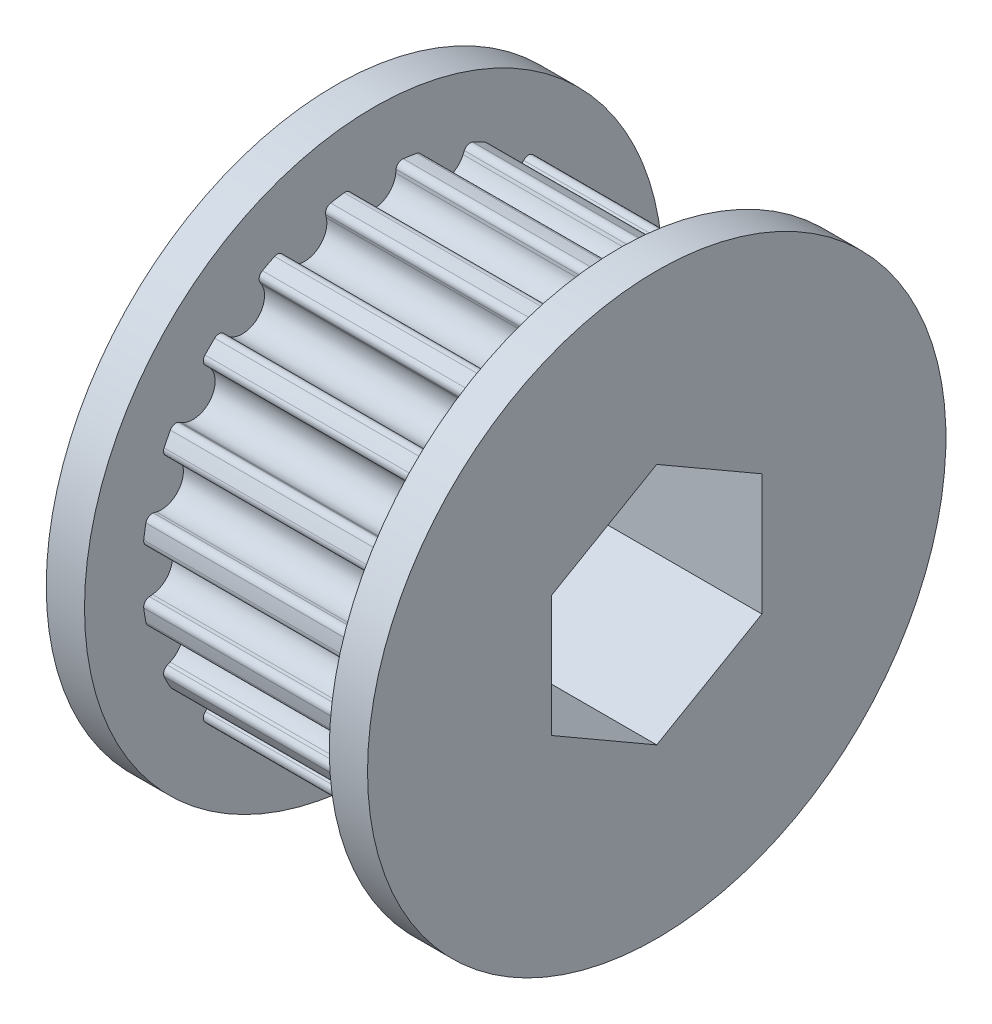
from build123d import *

# Parameters (mm, degrees)
SKETCH1_W           = 2.54
SKETCH1_H           = 19.205451693
BOSS_EXTRUDE1_DEPTH = 16.256
SKETCH3_R           = 19.205451693
BOSS_EXTRUDE2_DEPTH = 2.54
CUT_EXTRUDE1_DEPTH  = 22.336
FILLET1_R           = 0.42


with BuildPart() as part:
    # Sketch1 → Revolve1 (revolve)
    with BuildSketch(Plane(origin=(0, 0, 0), x_dir=(-1, 0, 0), z_dir=(0, 0, -1))):
        with Locations((-17.526, 9.602725847)):
            Rectangle(SKETCH1_W, SKETCH1_H)
    revolve(axis=Axis((18.796, 0, 0), (-1, 0, 0)))

    # Sketch2 → Boss-Extrude1 (add)
    with BuildSketch(Plane.ZY.offset(-16.256)):
        with BuildLine():
            Line((-14.690370829, 1.465919557), (-15.319368539, 1.528685845))
            ThreePointArc((-15.319368539, 1.528685845), (-15.205908136, 2.40837925), (-15.04197518, 3.280078587))
            Line((-15.04197518, 3.280078587), (-14.424366959, 3.145401892))
            ThreePointArc((-14.424366959, 3.145401892), (-12.709397813, 4.129533677), (-13.518378848, 5.933746587))
            Line((-13.518378848, 5.933746587), (-14.097195369, 6.187811856))
            ThreePointArc((-14.097195369, 6.187811856), (-13.717447902, 6.989388808), (-13.292168486, 7.767766074))
            Line((-13.292168486, 7.767766074), (-12.746405551, 7.448829489))
            ThreePointArc((-12.746405551, 7.448829489), (-10.811259523, 7.854839825), (-11.023113757, 9.820737158))
            Line((-11.023113757, 9.820737158), (-11.495090496, 10.241231729))
            ThreePointArc((-11.495090496, 10.241231729), (-10.886228292, 10.886228292), (-10.241231729, 11.495090496))
            Line((-10.241231729, 11.495090496), (-9.820737158, 11.023113757))
            ThreePointArc((-9.820737158, 11.023113757), (-7.854839825, 10.811259523), (-7.448829489, 12.746405551))
            Line((-7.448829489, 12.746405551), (-7.767766074, 13.292168486))
            ThreePointArc((-7.767766074, 13.292168486), (-6.989388808, 13.717447902), (-6.187811856, 14.097195369))
            Line((-6.187811856, 14.097195369), (-5.933746587, 13.518378848))
            ThreePointArc((-5.933746587, 13.518378848), (-4.129533677, 12.709397813), (-3.145401892, 14.424366959))
            Line((-3.145401892, 14.424366959), (-3.280078587, 15.04197518))
            ThreePointArc((-3.280078587, 15.04197518), (-2.40837925, 15.205908136), (-1.528685845, 15.319368539))
            Line((-1.528685845, 15.319368539), (-1.465919557, 14.690370829))
            ThreePointArc((-1.465919557, 14.690370829), (0, 13.363451693), (1.465919557, 14.690370829))
            Line((1.465919557, 14.690370829), (1.528685845, 15.319368539))
            ThreePointArc((1.528685845, 15.319368539), (2.40837925, 15.205908136), (3.280078587, 15.04197518))
            Line((3.280078587, 15.04197518), (3.145401892, 14.424366959))
            ThreePointArc((3.145401892, 14.424366959), (4.129533677, 12.709397813), (5.933746587, 13.518378848))
            Line((5.933746587, 13.518378848), (6.187811856, 14.097195369))
            ThreePointArc((6.187811856, 14.097195369), (6.989388808, 13.717447902), (7.767766074, 13.292168486))
            Line((7.767766074, 13.292168486), (7.448829489, 12.746405551))
            ThreePointArc((7.448829489, 12.746405551), (7.854839825, 10.811259523), (9.820737158, 11.023113757))
            Line((9.820737158, 11.023113757), (10.241231729, 11.495090496))
            ThreePointArc((10.241231729, 11.495090496), (10.886228292, 10.886228292), (11.495090496, 10.241231729))
            Line((11.495090496, 10.241231729), (11.023113757, 9.820737158))
            ThreePointArc((11.023113757, 9.820737158), (10.811259523, 7.854839825), (12.746405551, 7.448829489))
            Line((12.746405551, 7.448829489), (13.292168486, 7.767766074))
            ThreePointArc((13.292168486, 7.767766074), (13.717447902, 6.989388808), (14.097195369, 6.187811856))
            Line((14.097195369, 6.187811856), (13.518378848, 5.933746587))
            ThreePointArc((13.518378848, 5.933746587), (12.709397813, 4.129533677), (14.424366959, 3.145401892))
            Line((14.424366959, 3.145401892), (15.04197518, 3.280078587))
            ThreePointArc((15.04197518, 3.280078587), (15.205908136, 2.40837925), (15.319368539, 1.528685845))
            Line((15.319368539, 1.528685845), (14.690370829, 1.465919557))
            ThreePointArc((14.690370829, 1.465919557), (13.363451693, 0), (14.690370829, -1.465919557))
            Line((14.690370829, -1.465919557), (15.319368539, -1.528685845))
            ThreePointArc((15.319368539, -1.528685845), (15.205908136, -2.40837925), (15.04197518, -3.280078587))
            Line((15.04197518, -3.280078587), (14.424366959, -3.145401892))
            ThreePointArc((14.424366959, -3.145401892), (12.709397813, -4.129533677), (13.518378848, -5.933746587))
            Line((13.518378848, -5.933746587), (14.097195369, -6.187811856))
            ThreePointArc((14.097195369, -6.187811856), (13.717447902, -6.989388808), (13.292168486, -7.767766074))
            Line((13.292168486, -7.767766074), (12.746405551, -7.448829489))
            ThreePointArc((12.746405551, -7.448829489), (10.811259523, -7.854839825), (11.023113757, -9.820737158))
            Line((11.023113757, -9.820737158), (11.495090496, -10.241231729))
            ThreePointArc((11.495090496, -10.241231729), (10.886228292, -10.886228292), (10.241231729, -11.495090496))
            Line((10.241231729, -11.495090496), (9.820737158, -11.023113757))
            ThreePointArc((9.820737158, -11.023113757), (7.854839825, -10.811259523), (7.448829489, -12.746405551))
            Line((7.448829489, -12.746405551), (7.767766074, -13.292168486))
            ThreePointArc((7.767766074, -13.292168486), (6.989388808, -13.717447902), (6.187811856, -14.097195369))
            Line((6.187811856, -14.097195369), (5.933746587, -13.518378848))
            ThreePointArc((5.933746587, -13.518378848), (4.129533677, -12.709397813), (3.145401892, -14.424366959))
            Line((3.145401892, -14.424366959), (3.280078587, -15.04197518))
            ThreePointArc((3.280078587, -15.04197518), (2.40837925, -15.205908136), (1.528685845, -15.319368539))
            Line((1.528685845, -15.319368539), (1.465919557, -14.690370829))
            ThreePointArc((1.465919557, -14.690370829), (0, -13.363451693), (-1.465919557, -14.690370829))
            Line((-1.465919557, -14.690370829), (-1.528685845, -15.319368539))
            ThreePointArc((-1.528685845, -15.319368539), (-2.40837925, -15.205908136), (-3.280078587, -15.04197518))
            Line((-3.280078587, -15.04197518), (-3.145401892, -14.424366959))
            ThreePointArc((-3.145401892, -14.424366959), (-4.129533677, -12.709397813), (-5.933746587, -13.518378848))
            Line((-5.933746587, -13.518378848), (-6.187811856, -14.097195369))
            ThreePointArc((-6.187811856, -14.097195369), (-6.989388808, -13.717447902), (-7.767766074, -13.292168486))
            Line((-7.767766074, -13.292168486), (-7.448829489, -12.746405551))
            ThreePointArc((-7.448829489, -12.746405551), (-7.854839825, -10.811259523), (-9.820737158, -11.023113757))
            Line((-9.820737158, -11.023113757), (-10.241231729, -11.495090496))
            ThreePointArc((-10.241231729, -11.495090496), (-10.886228292, -10.886228292), (-11.495090496, -10.241231729))
            Line((-11.495090496, -10.241231729), (-11.023113757, -9.820737158))
            ThreePointArc((-11.023113757, -9.820737158), (-10.811259523, -7.854839825), (-12.746405551, -7.448829489))
            Line((-12.746405551, -7.448829489), (-13.292168486, -7.767766074))
            ThreePointArc((-13.292168486, -7.767766074), (-13.717447902, -6.989388808), (-14.097195369, -6.187811856))
            Line((-14.097195369, -6.187811856), (-13.518378848, -5.933746587))
            ThreePointArc((-13.518378848, -5.933746587), (-12.709397813, -4.129533677), (-14.424366959, -3.145401892))
            Line((-14.424366959, -3.145401892), (-15.04197518, -3.280078587))
            ThreePointArc((-15.04197518, -3.280078587), (-15.205908136, -2.40837925), (-15.319368539, -1.528685845))
            Line((-15.319368539, -1.528685845), (-14.690370829, -1.465919557))
            ThreePointArc((-14.690370829, -1.465919557), (-13.363451693, 0), (-14.690370829, 1.465919557))
        make_face()
    extrude(amount=BOSS_EXTRUDE1_DEPTH)

    # Sketch3 → Boss-Extrude2 (add)
    with BuildSketch(Plane(origin=(0, 0, 0), x_dir=(0, 0, -1), z_dir=(1, 0, 0))):
        Circle(SKETCH3_R)
    extrude(amount=-BOSS_EXTRUDE2_DEPTH)

    # Sketch4 → Cut-Extrude1 (cut, through all)
    with BuildSketch(Plane.ZY.offset(2.54)):
        Polygon((0, 8.065583261), (-6.985, 4.03279163), (-6.985, -4.03279163), (0, -8.065583261), (6.985, -4.03279163), (6.985, 4.03279163), align=None)
    extrude(amount=-CUT_EXTRUDE1_DEPTH, mode=Mode.SUBTRACT)

    # Fillet1
    fillet1_edges = [part.edges().sort_by_distance(p)[0] for p in [
        (8.128, -1.528685845, -15.319368539),
        (8.128, -3.280078587, -15.04197518),
        (8.128, -6.187811856, -14.097195369),
        (8.128, -7.767766074, -13.292168486),
        (8.128, -10.241231729, -11.495090496),
        (8.128, -11.495090496, -10.241231729),
        (8.128, -13.292168486, -7.767766074),
        (8.128, -14.097195369, -6.187811856),
        (8.128, -15.04197518, -3.280078587),
        (8.128, -15.319368539, -1.528685845),
        (8.128, -15.319368539, 1.528685845),
        (8.128, -15.04197518, 3.280078587),
        (8.128, -14.097195369, 6.187811856),
        (8.128, -13.292168486, 7.767766074),
        (8.128, -11.495090496, 10.241231729),
        (8.128, -10.241231729, 11.495090496),
        (8.128, -7.767766074, 13.292168486),
        (8.128, -6.187811856, 14.097195369),
        (8.128, -3.280078587, 15.04197518),
        (8.128, -1.528685845, 15.319368539),
        (8.128, 1.528685845, 15.319368539),
        (8.128, 3.280078587, 15.04197518),
        (8.128, 6.187811856, 14.097195369),
        (8.128, 7.767766074, 13.292168486),
        (8.128, 10.241231729, 11.495090496),
        (8.128, 11.495090496, 10.241231729),
        (8.128, 13.292168486, 7.767766074),
        (8.128, 14.097195369, 6.187811856),
        (8.128, 15.04197518, 3.280078587),
        (8.128, 15.319368539, 1.528685845),
        (8.128, 15.319368539, -1.528685845),
        (8.128, 15.04197518, -3.280078587),
        (8.128, 14.097195369, -6.187811856),
        (8.128, 13.292168486, -7.767766074),
        (8.128, 11.495090496, -10.241231729),
        (8.128, 10.241231729, -11.495090496),
        (8.128, 7.767766074, -13.292168486),
        (8.128, 6.187811856, -14.097195369),
        (8.128, 3.280078587, -15.04197518),
        (8.128, 1.528685845, -15.319368539),
    ]]
    fillet(fillet1_edges, radius=FILLET1_R)


solid = part.part
